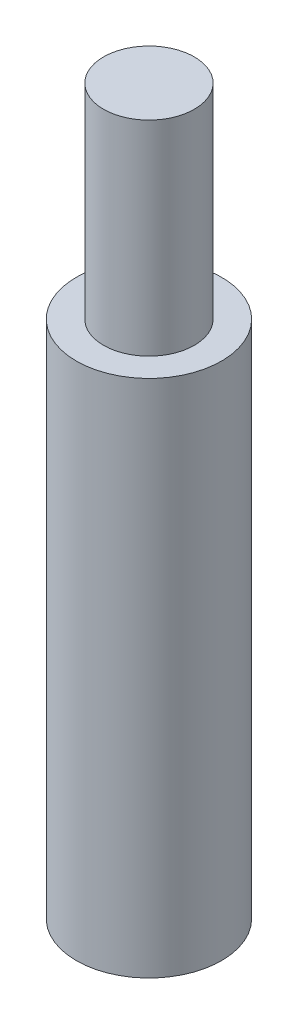
from build123d import *

# Parameters (mm, degrees)
SKETCH1_R           = 5.08
BOSS_EXTRUDE1_DEPTH = 50.620000106
SKETCH2_R           = 5.08
SKETCH2_R_2         = 3.175
CUT_EXTRUDE1_DEPTH  = 14.3


with BuildPart() as part:
    # Sketch1 → Boss-Extrude1 (new body)
    with BuildSketch(Plane(origin=(0, 0, 0), x_dir=(1, 0, 0), z_dir=(0, 1, 0))):
        Circle(SKETCH1_R)
    extrude(amount=BOSS_EXTRUDE1_DEPTH)

    # Sketch2 → Cut-Extrude1 (cut)
    with BuildSketch(Plane(origin=(0, 50.620000106, 0), x_dir=(1, 0, 0), z_dir=(0, 1, 0))):
        Circle(SKETCH2_R)
        Circle(SKETCH2_R_2, mode=Mode.SUBTRACT)
    extrude(amount=-CUT_EXTRUDE1_DEPTH, mode=Mode.SUBTRACT)


solid = part.part
